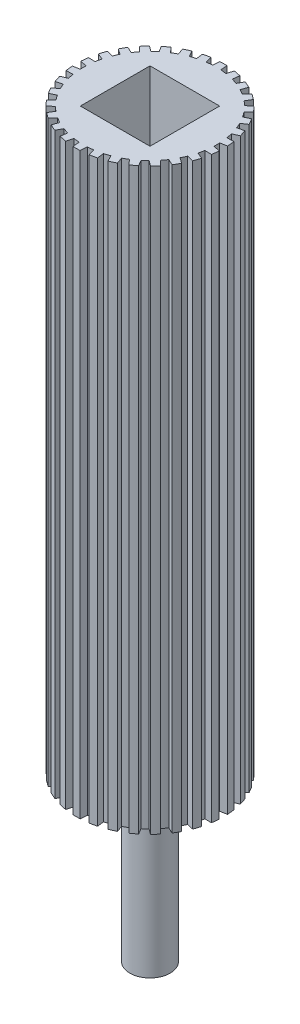
from build123d import *

# Parameters (mm, degrees)
BOSS_EXTRUDE1_DEPTH = 211.1375
SCALE2_SCALE_X      = 0.96
SCALE2_SCALE_Y      = 1
SCALE2_SCALE_Z      = 0.96
SKETCH3_R           = 3.68046
BOSS_EXTRUDE2_DEPTH = 29.55925
SKETCH4_R           = 3.68046
BOSS_EXTRUDE3_DEPTH = 29.55925
SKETCH6_R           = 20.636309267
CUT_EXTRUDE1_DEPTH  = 135.128
SKETCH7_W           = 12.7
SKETCH7_H           = 12.7
CUT_EXTRUDE2_DEPTH  = 12.7


with BuildPart() as part:
    # Sketch2 → Boss-Extrude1 (new body)
    with BuildSketch(Plane(origin=(0, 0, 0), x_dir=(1, 0, 0), z_dir=(0, 1, 0))):
        with BuildLine():
            Line((-0.775316452, 12.67631194), (-0.670254455, 13.953911959))
            ThreePointArc((-0.670254455, 13.953911959), (0, 13.97), (0.670254455, 13.953911959))
            Line((0.670254455, 13.953911959), (0.775316452, 12.67631194))
            ThreePointArc((0.775316452, 12.67631194), (1.327511483, 12.630428071), (1.877179521, 12.560501465))
            Line((1.877179521, 12.560501465), (2.245573641, 13.788339241))
            ThreePointArc((2.245573641, 13.788339241), (2.904526321, 13.664721982), (3.556789216, 13.509631767))
            Line((3.556789216, 13.509631767), (3.393927376, 12.238106756))
            ThreePointArc((3.393927376, 12.238106756), (3.924515829, 12.078417757), (4.447633742, 11.895736803))
            Line((4.447633742, 11.895736803), (5.063259395, 13.020149934))
            ThreePointArc((5.063259395, 13.020149934), (5.682110904, 12.762230043), (6.287875221, 12.474915839))
            Line((6.287875221, 12.474915839), (5.864207388, 11.265037581))
            ThreePointArc((5.864207388, 11.265037581), (6.35, 10.998522628), (6.823705026, 10.711071362))
            Line((6.823705026, 10.711071362), (7.659656416, 11.682917597))
            ThreePointArc((7.659656416, 11.682917597), (8.211359975, 11.301967411), (8.744150906, 10.894986229))
            Line((8.744150906, 10.894986229), (8.078193398, 9.799632209))
            ThreePointArc((8.078193398, 9.799632209), (8.497958701, 9.437939284), (8.901547657, 9.058280704))
            Line((8.901547657, 9.058280704), (9.921289697, 9.835085701))
            ThreePointArc((9.921289697, 9.835085701), (10.381733212, 9.347754571), (10.818265238, 8.83889344))
            Line((10.818265238, 8.83889344), (9.939123592, 7.905935885))
            ThreePointArc((9.939123592, 7.905935885), (10.274515829, 7.464872704), (10.59034994, 7.009599713))
            Line((10.59034994, 7.009599713), (11.749315011, 7.557413365))
            ThreePointArc((11.749315011, 7.557413365), (12.098374891, 6.985), (12.419569467, 6.396498594))
            Line((12.419569467, 6.396498594), (11.365666392, 5.666712226))
            ThreePointArc((11.365666392, 5.666712226), (11.602027312, 5.165555367), (11.816303113, 4.654565579))
            Line((11.816303113, 4.654565579), (13.063838879, 4.949445801))
            ThreePointArc((13.063838879, 4.949445801), (13.286259533, 4.316967411), (13.478078914, 3.674546066))
            Line((13.478078914, 3.674546066), (12.295475033, 3.179826051))
            ThreePointArc((12.295475033, 3.179826051), (12.422474529, 2.640478473), (12.52582714, 2.096104594))
            Line((12.52582714, 2.096104594), (13.807410301, 2.125163705))
            ThreePointArc((13.807410301, 2.125163705), (13.893470878, 1.460262632), (13.947531638, 0.791998242))
            Line((13.947531638, 0.791998242), (12.687912414, 0.55396622))
            ThreePointArc((12.687912414, 0.55396622), (12.7, 0), (12.687912414, -0.55396622))
            Line((12.687912414, -0.55396622), (13.947531638, -0.791998242))
            ThreePointArc((13.947531638, -0.791998242), (13.893470878, -1.460262632), (13.807410301, -2.125163705))
            Line((13.807410301, -2.125163705), (12.52582714, -2.096104594))
            ThreePointArc((12.52582714, -2.096104594), (12.422474529, -2.640478473), (12.295475033, -3.179826051))
            Line((12.295475033, -3.179826051), (13.478078914, -3.674546066))
            ThreePointArc((13.478078914, -3.674546066), (13.286259533, -4.316967411), (13.063838879, -4.949445801))
            Line((13.063838879, -4.949445801), (11.816303113, -4.654565579))
            ThreePointArc((11.816303113, -4.654565579), (11.602027312, -5.165555367), (11.365666392, -5.666712226))
            Line((11.365666392, -5.666712226), (12.419569467, -6.396498594))
            ThreePointArc((12.419569467, -6.396498594), (12.098374891, -6.985), (11.749315011, -7.557413365))
            Line((11.749315011, -7.557413365), (10.59034994, -7.009599713))
            ThreePointArc((10.59034994, -7.009599713), (10.274515829, -7.464872704), (9.939123592, -7.905935885))
            Line((9.939123592, -7.905935885), (10.818265238, -8.83889344))
            ThreePointArc((10.818265238, -8.83889344), (10.381733212, -9.347754571), (9.921289697, -9.835085701))
            Line((9.921289697, -9.835085701), (8.901547657, -9.058280704))
            ThreePointArc((8.901547657, -9.058280704), (8.497958701, -9.437939284), (8.078193398, -9.799632209))
            Line((8.078193398, -9.799632209), (8.744150906, -10.894986229))
            ThreePointArc((8.744150906, -10.894986229), (8.211359975, -11.301967411), (7.659656416, -11.682917597))
            Line((7.659656416, -11.682917597), (6.823705026, -10.711071362))
            ThreePointArc((6.823705026, -10.711071362), (6.35, -10.998522628), (5.864207388, -11.265037581))
            Line((5.864207388, -11.265037581), (6.287875221, -12.474915839))
            ThreePointArc((6.287875221, -12.474915839), (5.682110904, -12.762230043), (5.063259395, -13.020149934))
            Line((5.063259395, -13.020149934), (4.447633742, -11.895736803))
            ThreePointArc((4.447633742, -11.895736803), (3.924515829, -12.078417757), (3.393927376, -12.238106756))
            Line((3.393927376, -12.238106756), (3.556789216, -13.509631767))
            ThreePointArc((3.556789216, -13.509631767), (2.904526321, -13.664721982), (2.245573641, -13.788339241))
            Line((2.245573641, -13.788339241), (1.877179521, -12.560501465))
            ThreePointArc((1.877179521, -12.560501465), (1.327511483, -12.630428071), (0.775316452, -12.67631194))
            Line((0.775316452, -12.67631194), (0.670254455, -13.953911959))
            ThreePointArc((0.670254455, -13.953911959), (0, -13.97), (-0.670254455, -13.953911959))
            Line((-0.670254455, -13.953911959), (-0.775316452, -12.67631194))
            ThreePointArc((-0.775316452, -12.67631194), (-1.327511483, -12.630428071), (-1.877179521, -12.560501465))
            Line((-1.877179521, -12.560501465), (-2.245573641, -13.788339241))
            ThreePointArc((-2.245573641, -13.788339241), (-2.904526321, -13.664721982), (-3.556789216, -13.509631767))
            Line((-3.556789216, -13.509631767), (-3.393927376, -12.238106756))
            ThreePointArc((-3.393927376, -12.238106756), (-3.924515829, -12.078417757), (-4.447633742, -11.895736803))
            Line((-4.447633742, -11.895736803), (-5.063259395, -13.020149934))
            ThreePointArc((-5.063259395, -13.020149934), (-5.682110904, -12.762230043), (-6.287875221, -12.474915839))
            Line((-6.287875221, -12.474915839), (-5.864207388, -11.265037581))
            ThreePointArc((-5.864207388, -11.265037581), (-6.35, -10.998522628), (-6.823705026, -10.711071362))
            Line((-6.823705026, -10.711071362), (-7.659656416, -11.682917597))
            ThreePointArc((-7.659656416, -11.682917597), (-8.211359975, -11.301967411), (-8.744150906, -10.894986229))
            Line((-8.744150906, -10.894986229), (-8.078193398, -9.799632209))
            ThreePointArc((-8.078193398, -9.799632209), (-8.497958701, -9.437939284), (-8.901547657, -9.058280704))
            Line((-8.901547657, -9.058280704), (-9.921289697, -9.835085701))
            ThreePointArc((-9.921289697, -9.835085701), (-10.381733212, -9.347754571), (-10.818265238, -8.83889344))
            Line((-10.818265238, -8.83889344), (-9.939123592, -7.905935885))
            ThreePointArc((-9.939123592, -7.905935885), (-10.274515829, -7.464872704), (-10.59034994, -7.009599713))
            Line((-10.59034994, -7.009599713), (-11.749315011, -7.557413365))
            ThreePointArc((-11.749315011, -7.557413365), (-12.098374891, -6.985), (-12.419569467, -6.396498594))
            Line((-12.419569467, -6.396498594), (-11.365666392, -5.666712226))
            ThreePointArc((-11.365666392, -5.666712226), (-11.602027312, -5.165555367), (-11.816303113, -4.654565579))
            Line((-11.816303113, -4.654565579), (-13.063838879, -4.949445801))
            ThreePointArc((-13.063838879, -4.949445801), (-13.286259533, -4.316967411), (-13.478078914, -3.674546066))
            Line((-13.478078914, -3.674546066), (-12.295475033, -3.179826051))
            ThreePointArc((-12.295475033, -3.179826051), (-12.422474529, -2.640478473), (-12.52582714, -2.096104594))
            Line((-12.52582714, -2.096104594), (-13.807410301, -2.125163705))
            ThreePointArc((-13.807410301, -2.125163705), (-13.893470878, -1.460262632), (-13.947531638, -0.791998242))
            Line((-13.947531638, -0.791998242), (-12.687912414, -0.55396622))
            ThreePointArc((-12.687912414, -0.55396622), (-12.7, 0), (-12.687912414, 0.55396622))
            Line((-12.687912414, 0.55396622), (-13.947531638, 0.791998242))
            ThreePointArc((-13.947531638, 0.791998242), (-13.893470878, 1.460262632), (-13.807410301, 2.125163705))
            Line((-13.807410301, 2.125163705), (-12.52582714, 2.096104594))
            ThreePointArc((-12.52582714, 2.096104594), (-12.422474529, 2.640478473), (-12.295475033, 3.179826051))
            Line((-12.295475033, 3.179826051), (-13.478078914, 3.674546066))
            ThreePointArc((-13.478078914, 3.674546066), (-13.286259533, 4.316967411), (-13.063838879, 4.949445801))
            Line((-13.063838879, 4.949445801), (-11.816303113, 4.654565579))
            ThreePointArc((-11.816303113, 4.654565579), (-11.602027312, 5.165555367), (-11.365666392, 5.666712226))
            Line((-11.365666392, 5.666712226), (-12.419569467, 6.396498594))
            ThreePointArc((-12.419569467, 6.396498594), (-12.098374891, 6.985), (-11.749315011, 7.557413365))
            Line((-11.749315011, 7.557413365), (-10.59034994, 7.009599713))
            ThreePointArc((-10.59034994, 7.009599713), (-10.274515829, 7.464872704), (-9.939123592, 7.905935885))
            Line((-9.939123592, 7.905935885), (-10.818265238, 8.83889344))
            ThreePointArc((-10.818265238, 8.83889344), (-10.381733212, 9.347754571), (-9.921289697, 9.835085701))
            Line((-9.921289697, 9.835085701), (-8.901547657, 9.058280704))
            ThreePointArc((-8.901547657, 9.058280704), (-8.497958701, 9.437939284), (-8.078193398, 9.799632209))
            Line((-8.078193398, 9.799632209), (-8.744150906, 10.894986229))
            ThreePointArc((-8.744150906, 10.894986229), (-8.211359975, 11.301967411), (-7.659656416, 11.682917597))
            Line((-7.659656416, 11.682917597), (-6.823705026, 10.711071362))
            ThreePointArc((-6.823705026, 10.711071362), (-6.35, 10.998522628), (-5.864207388, 11.265037581))
            Line((-5.864207388, 11.265037581), (-6.287875221, 12.474915839))
            ThreePointArc((-6.287875221, 12.474915839), (-5.682110904, 12.762230043), (-5.063259395, 13.020149934))
            Line((-5.063259395, 13.020149934), (-4.447633742, 11.895736803))
            ThreePointArc((-4.447633742, 11.895736803), (-3.924515829, 12.078417757), (-3.393927376, 12.238106756))
            Line((-3.393927376, 12.238106756), (-3.556789216, 13.509631767))
            ThreePointArc((-3.556789216, 13.509631767), (-2.904526321, 13.664721982), (-2.245573641, 13.788339241))
            Line((-2.245573641, 13.788339241), (-1.877179521, 12.560501465))
            ThreePointArc((-1.877179521, 12.560501465), (-1.327511483, 12.630428071), (-0.775316452, 12.67631194))
        make_face()
    extrude(amount=BOSS_EXTRUDE1_DEPTH)


with BuildPart() as part_1:
    # Scale2: scaled about (0, 105.56875, 0)
    add(part.part.scale((SCALE2_SCALE_X, SCALE2_SCALE_Y, SCALE2_SCALE_Z), about=(0, 105.56875, 0)))

    # Sketch3 → Boss-Extrude2 (add)
    with BuildSketch(Plane(origin=(0, 211.1375, 0), x_dir=(1, 0, 0), z_dir=(0, 1, 0))):
        Circle(SKETCH3_R)
    extrude(amount=BOSS_EXTRUDE2_DEPTH)

    # Sketch4 → Boss-Extrude3 (add)
    with BuildSketch(Plane(origin=(0, 0, 0), x_dir=(-1, 0, 0), z_dir=(0, -1, 0))):
        Circle(SKETCH4_R)
    extrude(amount=BOSS_EXTRUDE3_DEPTH)

    # Sketch6 → Cut-Extrude1 (cut)
    with BuildSketch(Plane(origin=(0, 240.69675, 0), x_dir=(1, 0, 0), z_dir=(0, 1, 0))):
        Circle(SKETCH6_R)
    extrude(amount=-CUT_EXTRUDE1_DEPTH, mode=Mode.SUBTRACT)

    # Sketch7 → Cut-Extrude2 (cut)
    with BuildSketch(Plane(origin=(0, 105.56875, 0), x_dir=(1, 0, 0), z_dir=(0, 1, 0))):
        Rectangle(SKETCH7_W, SKETCH7_H)
    extrude(amount=-CUT_EXTRUDE2_DEPTH, mode=Mode.SUBTRACT)


solid = part_1.part
